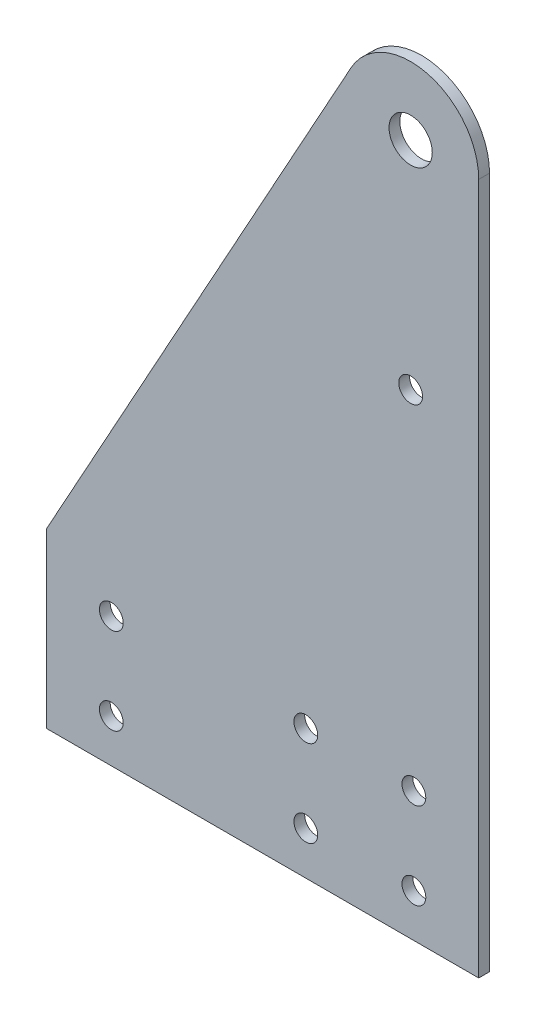
from build123d import *

# Parameters (mm, degrees)
SKETCH1_R           = 6.35
SKETCH1_R_2         = 3.5
BOSS_EXTRUDE1_DEPTH = 3.175


with BuildPart() as part:
    # Sketch1 → Boss-Extrude1 (new body)
    with BuildSketch(Plane.XY):
        with BuildLine():
            Line((-63.5, -25.4), (63.5, -25.4))
            Line((63.5, -25.4), (63.5, 177.8))
            ThreePointArc((63.5, 177.8), (48.491876086, 197.167012499), (25.991882686, 187.467772655))
            Line((25.991882686, 187.467772655), (-63.5, 25.4))
            Line((-63.5, 25.4), (-63.5, -25.4))
        make_face()
        with Locations((43.5, 177.8)):
            Circle(SKETCH1_R, mode=Mode.SUBTRACT)
        with Locations((-44.45, 12.7)):
            Circle(SKETCH1_R_2, mode=Mode.SUBTRACT)
        with Locations((44.45, 12.7)):
            Circle(SKETCH1_R_2, mode=Mode.SUBTRACT)
        with Locations((44.45, -12.7)):
            Circle(SKETCH1_R_2, mode=Mode.SUBTRACT)
        with Locations((-44.45, -12.7)):
            Circle(SKETCH1_R_2, mode=Mode.SUBTRACT)
        with Locations((12.7, 12.7)):
            Circle(SKETCH1_R_2, mode=Mode.SUBTRACT)
        with Locations((12.7, -12.7)):
            Circle(SKETCH1_R_2, mode=Mode.SUBTRACT)
        with Locations((43.5, 114.3)):
            Circle(SKETCH1_R_2, mode=Mode.SUBTRACT)
    extrude(amount=BOSS_EXTRUDE1_DEPTH)


solid = part.part
